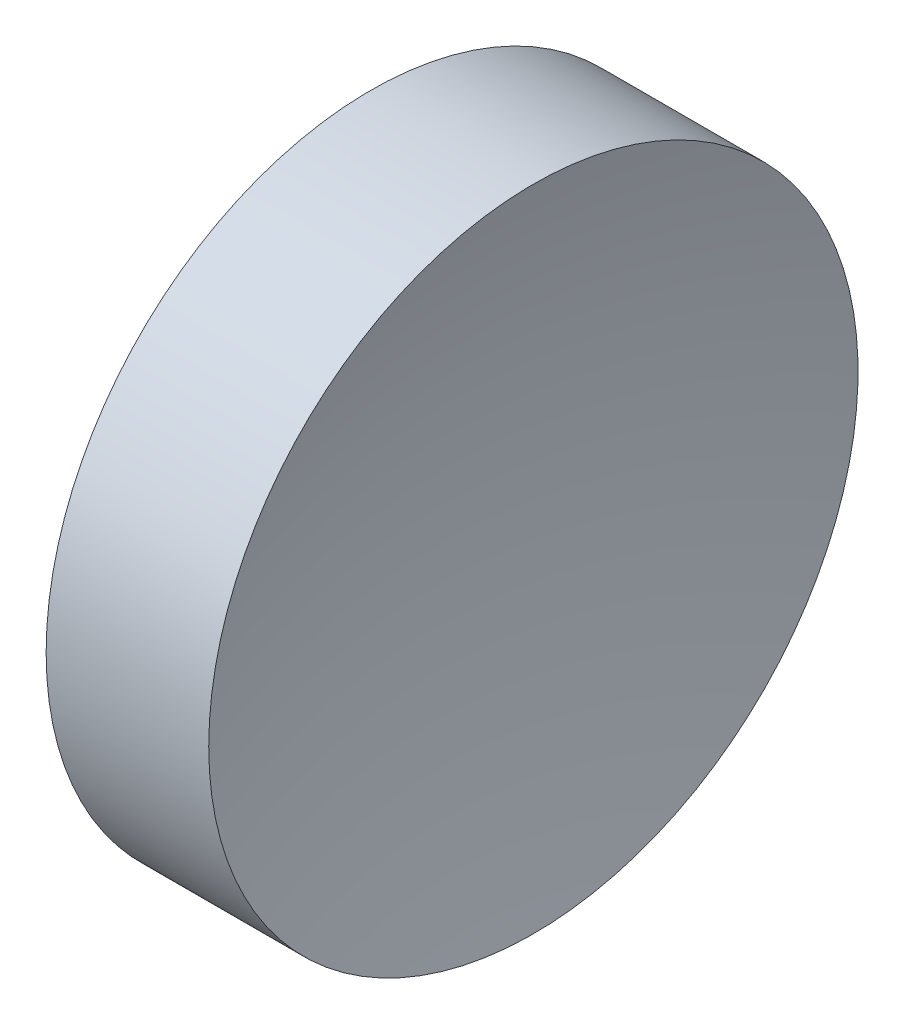
from build123d import *


with BuildPart() as part:
    # 草图1 → 旋转1 (revolve)
    with BuildSketch(Plane(origin=(0, 0, 0), x_dir=(1, 0, 0), z_dir=(0, 1, 0)), mode=Mode.PRIVATE) as revolve_1_sk:
        with BuildLine():
            Line((0, 0), (2.36, 0))
            ThreePointArc((2.36, 0), (2.56582088, 3.201356238), (3.179894541, 6.35))
            Line((3.179894541, 6.35), (0, 6.35))
            Line((0, 6.35), (0, 0))
        make_face()
    revolve(revolve_1_sk.sketch.rotate(Axis((0, 0, 0), (1, 0, 0)), 180), axis=Axis((0, 0, 0), (1, 0, 0)))  # turned: the seam where the file's is


solid = part.part
